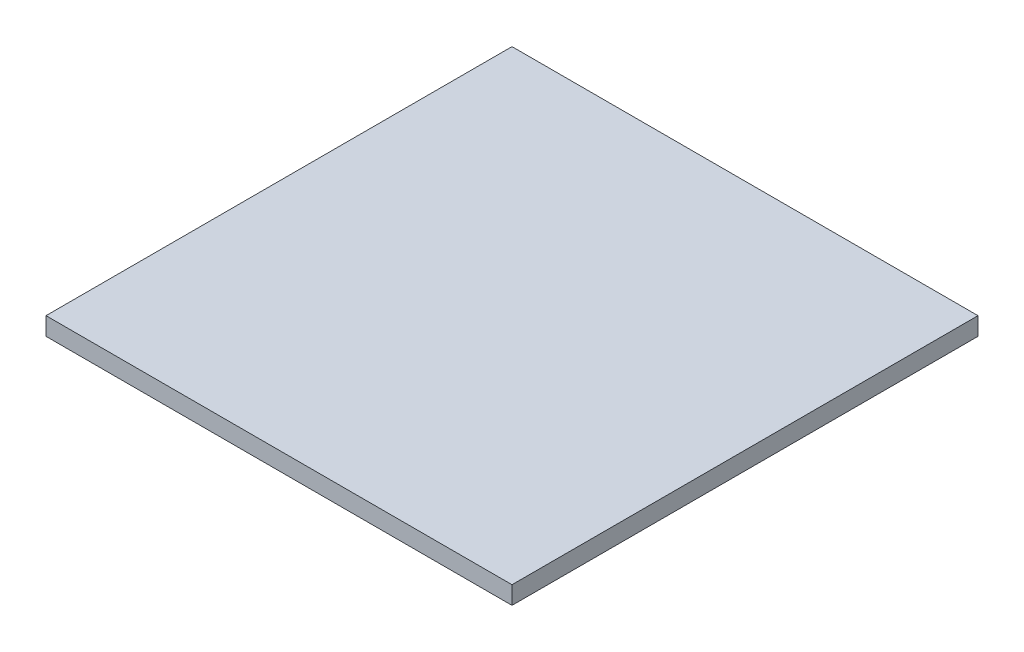
from build123d import *

# Parameters (mm, degrees)
SKETCH1_W           = 165.1
SKETCH1_H           = 165.1
BOSS_EXTRUDE1_DEPTH = 6.35


with BuildPart() as part:
    # Sketch1 → Boss-Extrude1 (new body)
    with BuildSketch(Plane(origin=(0, 0, 0), x_dir=(1, 0, 0), z_dir=(0, 1, 0))):
        with Locations((21.895214286, 39.017857143)):
            Rectangle(SKETCH1_W, SKETCH1_H)
    extrude(amount=BOSS_EXTRUDE1_DEPTH)


solid = part.part
